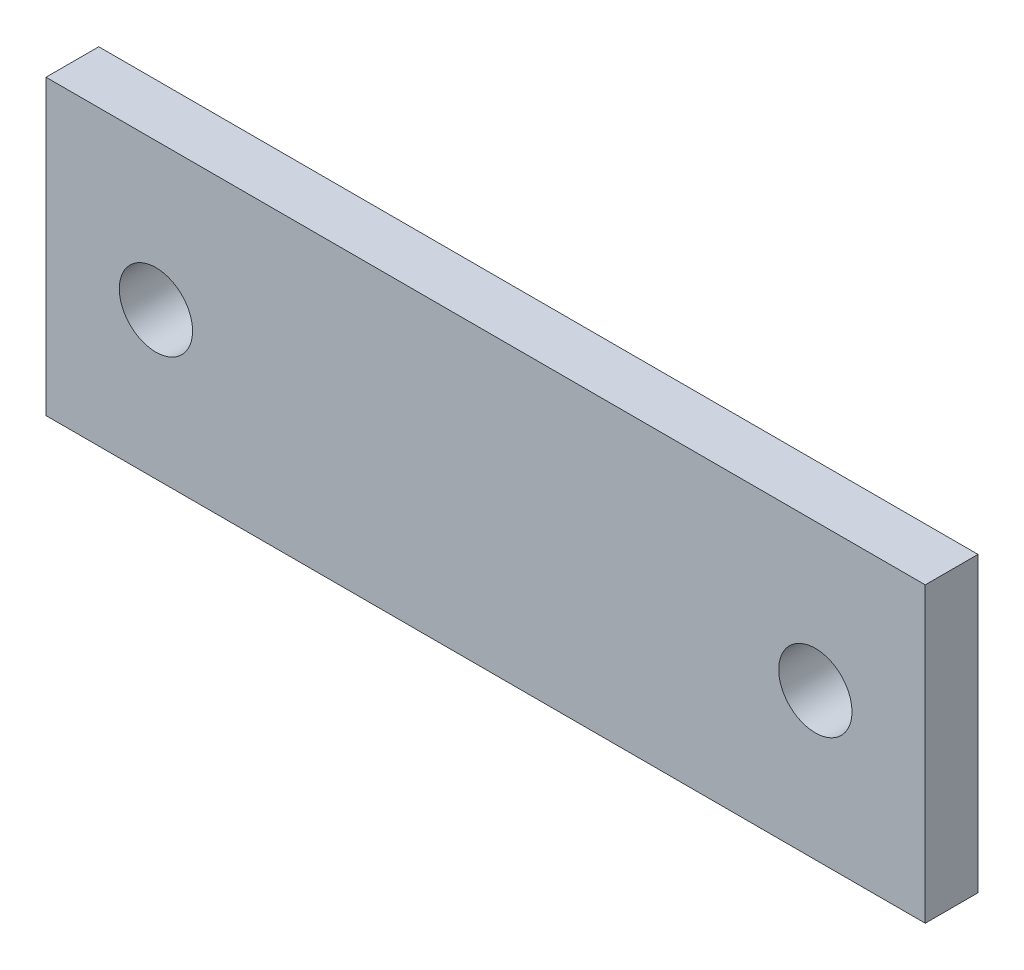
from build123d import *

# Parameters (mm, degrees)
SKETCH1_W           = 76.2
SKETCH1_H           = 25.4
SKETCH1_R           = 3.175
BOSS_EXTRUDE1_DEPTH = 4.572


with BuildPart() as part:
    # Sketch1 → Boss-Extrude1 (new body)
    with BuildSketch(Plane.XY):
        Rectangle(SKETCH1_W, SKETCH1_H)
        with Locations((-28.575, 0)):
            Circle(SKETCH1_R, mode=Mode.SUBTRACT)
        with Locations((28.575, 0)):
            Circle(SKETCH1_R, mode=Mode.SUBTRACT)
    extrude(amount=-BOSS_EXTRUDE1_DEPTH)


solid = part.part
